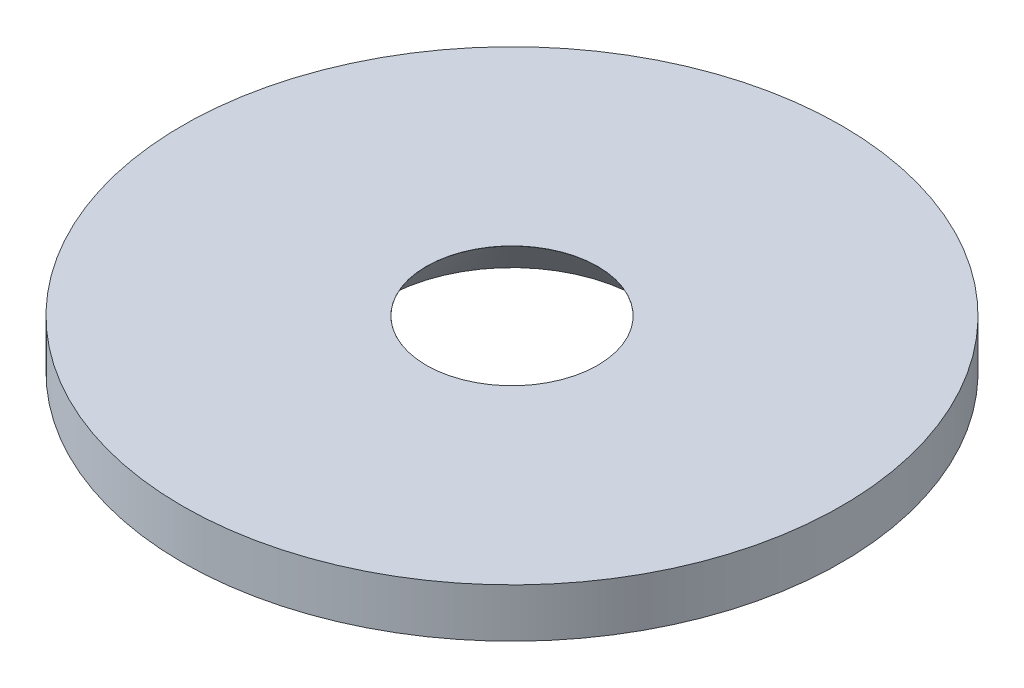
from build123d import *

# Parameters (mm, degrees)
SKETCH1_R           = 13.5
SKETCH1_R_2         = 3.51
BOSS_EXTRUDE1_DEPTH = 2


with BuildPart() as part:
    # Sketch1 → Boss-Extrude1 (new body)
    with BuildSketch(Plane(origin=(0, 0, 0), x_dir=(1, 0, 0), z_dir=(0, 1, 0))):
        Circle(SKETCH1_R)
        Circle(SKETCH1_R_2, mode=Mode.SUBTRACT)
    extrude(amount=BOSS_EXTRUDE1_DEPTH)

    # Sketch2 → Cut-Revolve1 (revolve, cut)
    with BuildSketch(Plane(origin=(0, 0, 0), x_dir=(0, 0, -1), z_dir=(1, 0, 0))):
        Polygon((-3.505, 2), (-5.24727164, 0), (-3.505, 0), align=None)
    revolve(axis=Axis((0, -2.060833688, 0), (0, 1, 0)), mode=Mode.SUBTRACT)


solid = part.part
